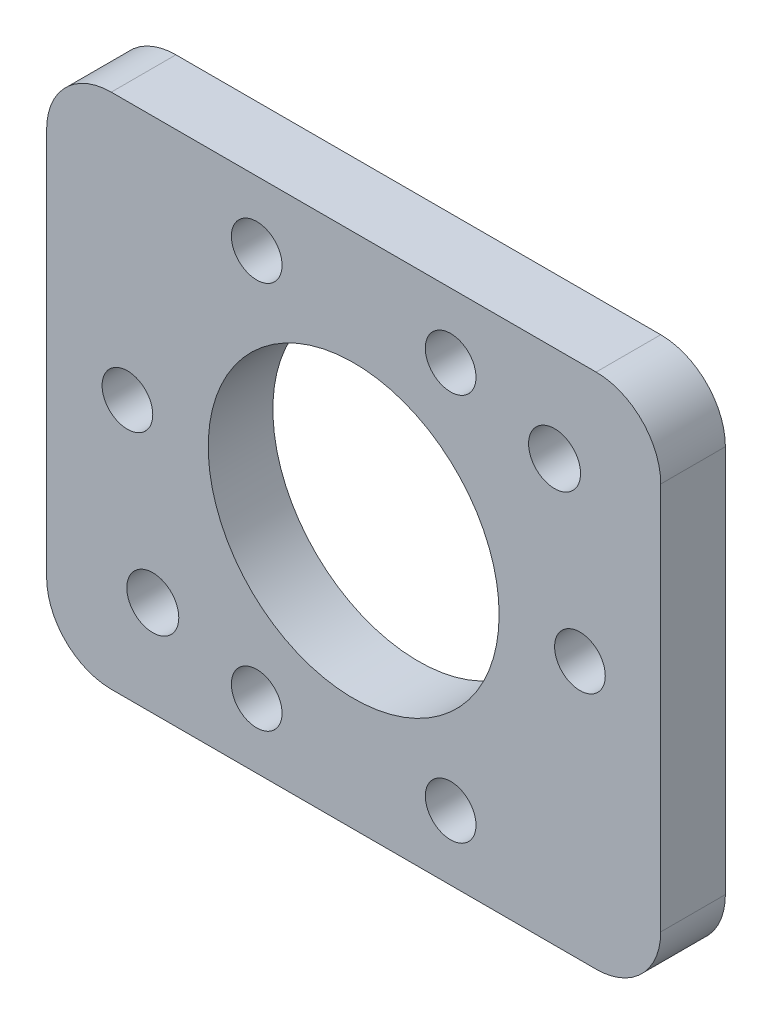
from build123d import *

# Parameters (mm, degrees)
SKETCH1_W           = 60.325
SKETCH1_H           = 50.8
SKETCH1_R           = 2.4892
SKETCH1_R_2         = 2.5527
SKETCH1_R_3         = 14.2875
BOSS_EXTRUDE1_DEPTH = 6.35
FILLET1_R           = 6.35


with BuildPart() as part:
    # Sketch1 → Boss-Extrude1 (new body)
    with BuildSketch(Plane.XY):
        Rectangle(SKETCH1_W, SKETCH1_H)
        with Locations((-9.525, -19.05)):
            Circle(SKETCH1_R, mode=Mode.SUBTRACT)
        with Locations((9.525, -19.05)):
            Circle(SKETCH1_R, mode=Mode.SUBTRACT)
        with Locations((9.525, 19.05)):
            Circle(SKETCH1_R, mode=Mode.SUBTRACT)
        with Locations((-9.525, 19.05)):
            Circle(SKETCH1_R, mode=Mode.SUBTRACT)
        with Locations((22.225, 0)):
            Circle(SKETCH1_R, mode=Mode.SUBTRACT)
        with Locations((-22.225, 0)):
            Circle(SKETCH1_R, mode=Mode.SUBTRACT)
        with Locations((-19.731795339, -15.994256867)):
            Circle(SKETCH1_R_2, mode=Mode.SUBTRACT)
        with Locations((19.731795339, 15.994256867)):
            Circle(SKETCH1_R_2, mode=Mode.SUBTRACT)
        Circle(SKETCH1_R_3, mode=Mode.SUBTRACT)
    extrude(amount=BOSS_EXTRUDE1_DEPTH)

    # Fillet1
    fillet1_edges = [part.edges().sort_by_distance(p)[0] for p in [
        (30.1625, -25.4, 3.175),
        (-30.1625, -25.4, 3.175),
        (-30.1625, 25.4, 3.175),
        (30.1625, 25.4, 3.175),
    ]]
    fillet(fillet1_edges, radius=FILLET1_R)


solid = part.part
